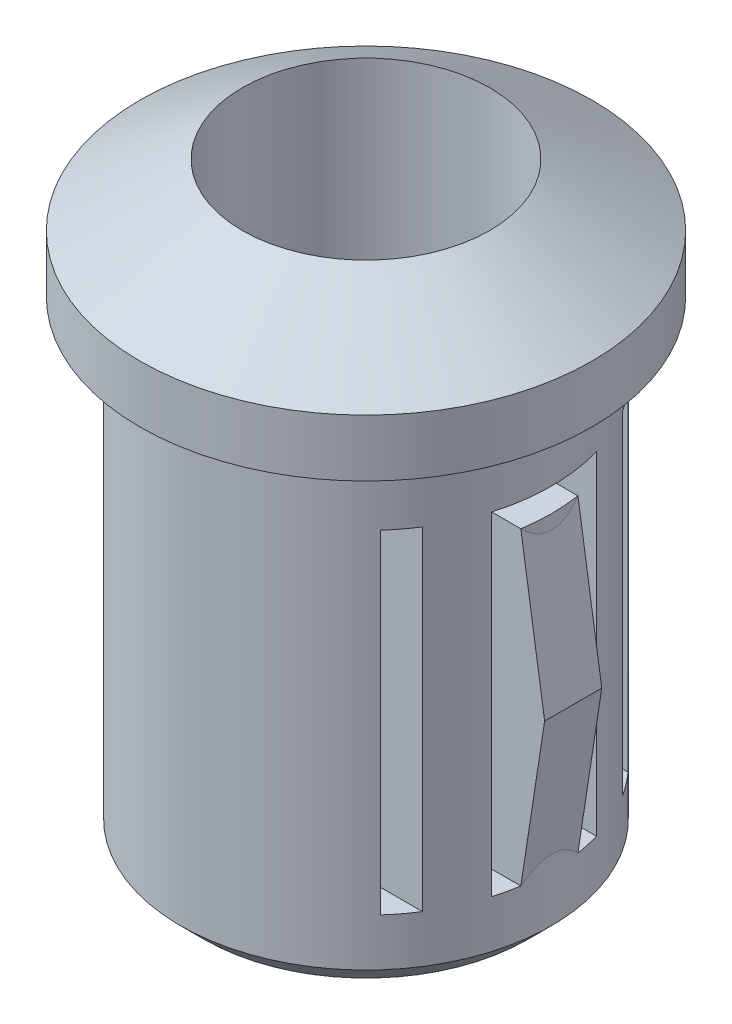
from build123d import *

# Parameters (mm, degrees)
SKETCH2_W               = 0.5
SKETCH2_H               = 7
CUT_EXTRUDE1_DEPTH      = 5.75
CUT_EXTRUDE1_DEPTH_BACK = 5.75
BOSS_EXTRUDE1_DEPTH     = 1.2
CHAMFER1_SIZE           = 0.5


with BuildPart() as part:
    # Sketch1 → Revolve1 (revolve)
    with BuildSketch(Plane.XY):
        Polygon((2.6, 0), (2.6, 4), (4.75, 2.7), (4.75, 1.5), (3.9, 1.5), (3.9, -8.5), (3.1, -8.5), (3.1, 0), align=None)
    revolve(axis=Axis((0, 42.244045278, 0), (0, -1, 0)))

    # Sketch2 → Cut-Extrude1 (cut, two sides)
    with BuildSketch(Plane(origin=(0, 0, 0), x_dir=(0, 0, -1), z_dir=(1, 0, 0))) as cut_extrude1_sk:
        Polygon((0.6, -7), (1.1, -7), (1.1, 0), (-1.1, 0), (-1.1, -7), (-0.6, -7), (-0.6, -0.5), (0.6, -0.5), align=None)
        with Locations((-2.35, -3.5)):
            Rectangle(SKETCH2_W, SKETCH2_H)
        with Locations((2.35, -3.5)):
            Rectangle(SKETCH2_W, SKETCH2_H)
    extrude(amount=CUT_EXTRUDE1_DEPTH, mode=Mode.SUBTRACT)
    extrude(cut_extrude1_sk.sketch, amount=-CUT_EXTRUDE1_DEPTH_BACK, mode=Mode.SUBTRACT)

    # Sketch3 → Boss-Extrude1 (add)
    with BuildSketch(Plane.XY.offset(0.6)):
        Polygon((3.853569774, -0.5), (4.353569774, -3.75), (3.853569774, -7), align=None)
    boss_extrude1 = extrude(amount=-BOSS_EXTRUDE1_DEPTH)

    # Mirror1: Boss-Extrude1 across plane
    add(boss_extrude1.mirror(Plane(origin=(0, 0, 0), x_dir=(0, 0, 1), z_dir=(1, 0, 0))))

    # Chamfer1
    chamfer1_edges = [part.edges().sort_by_distance(p)[0] for p in [
        (-3.9, -8.5, 0),
    ]]
    chamfer(chamfer1_edges, length=CHAMFER1_SIZE)


solid = part.part
